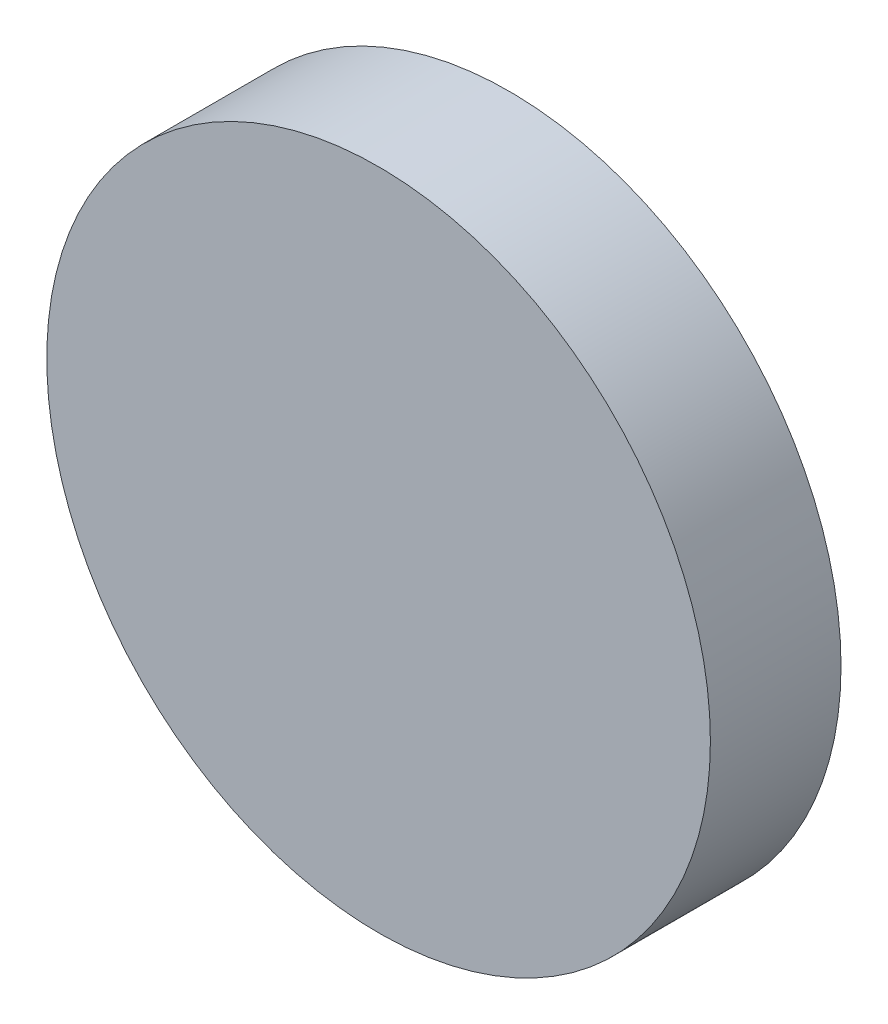
from build123d import *

# Parameters (mm, degrees)
SKETCH_1_R      = 12.7
EXTRUDE_1_DEPTH = 5


with BuildPart() as part:
    # 草图1 → 凸台-拉伸1 (new body)
    with BuildSketch(Plane.XY):
        Circle(SKETCH_1_R)
    extrude(amount=EXTRUDE_1_DEPTH)


solid = part.part
